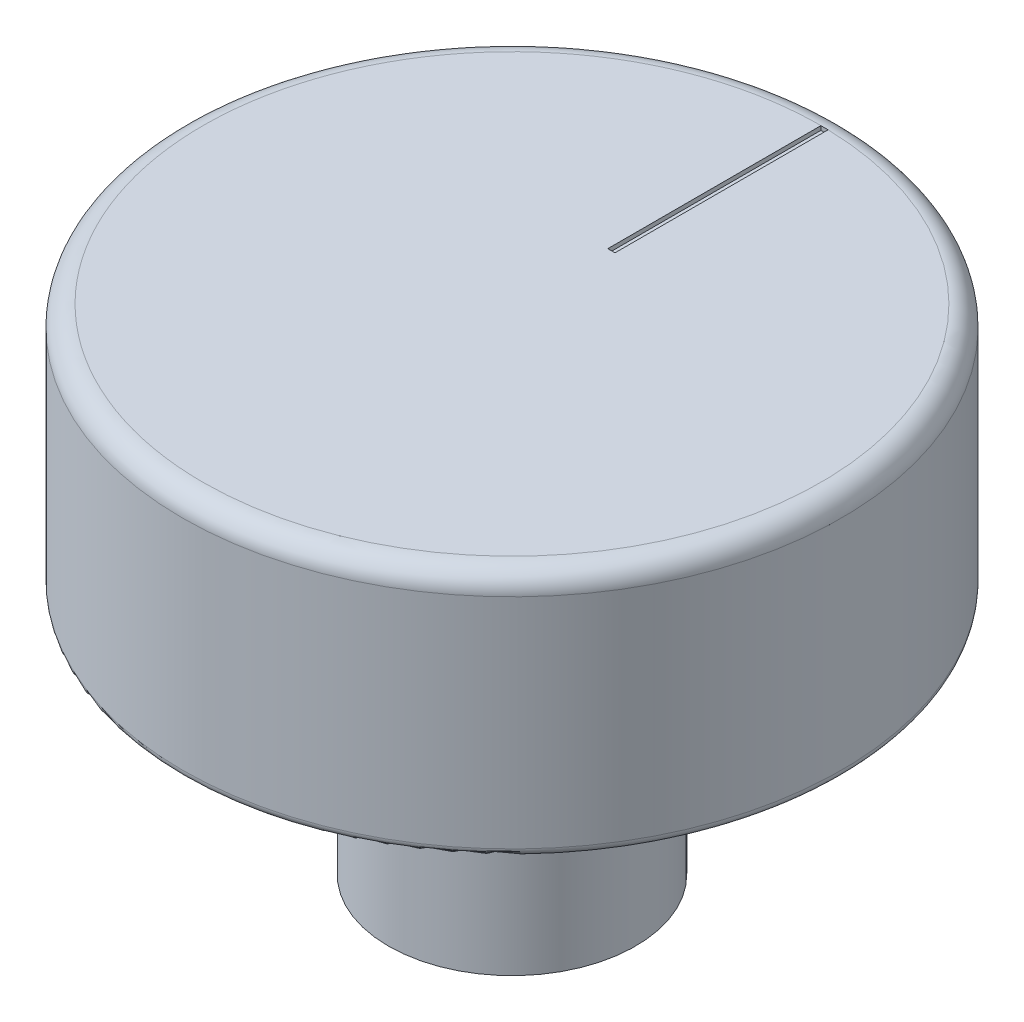
from build123d import *

# Parameters (mm, degrees)
SKETCH1_R           = 3
BOSS_EXTRUDE1_DEPTH = 6
SKETCH2_R           = 8
BOSS_EXTRUDE2_DEPTH = 6
FILLET2_R           = 0.2
FILLET3_R           = 0.5
SKETCH5_W           = 0.175185834
SKETCH5_H           = 5.17248517
CUT_EXTRUDE1_DEPTH  = 0.1


with BuildPart() as part:
    # Sketch1 → Boss-Extrude1 (new body)
    with BuildSketch(Plane(origin=(0, 0, 0), x_dir=(1, 0, 0), z_dir=(0, 1, 0))):
        Circle(SKETCH1_R)
    extrude(amount=BOSS_EXTRUDE1_DEPTH)

    # Sketch2 → Boss-Extrude2 (add)
    with BuildSketch(Plane(origin=(0, 6, 0), x_dir=(1, 0, 0), z_dir=(0, 1, 0))):
        Circle(SKETCH2_R)
    extrude(amount=BOSS_EXTRUDE2_DEPTH)

    # Fillet2
    fillet2_edges = [part.edges().sort_by_distance(p)[0] for p in [
        (-8, 6, 0),
    ]]
    fillet(fillet2_edges, radius=FILLET2_R)

    # Fillet3
    fillet3_edges = [part.edges().sort_by_distance(p)[0] for p in [
        (-8, 12, 0),
    ]]
    fillet(fillet3_edges, radius=FILLET3_R)

    # Sketch5 → Cut-Extrude1 (cut)
    with BuildSketch(Plane(origin=(0, 12, 0), x_dir=(1, 0, 0), z_dir=(0, 1, 0))):
        with Locations((0.087592917, 4.911711131)):
            Rectangle(SKETCH5_W, SKETCH5_H)
    extrude(amount=-CUT_EXTRUDE1_DEPTH, mode=Mode.SUBTRACT)


solid = part.part
